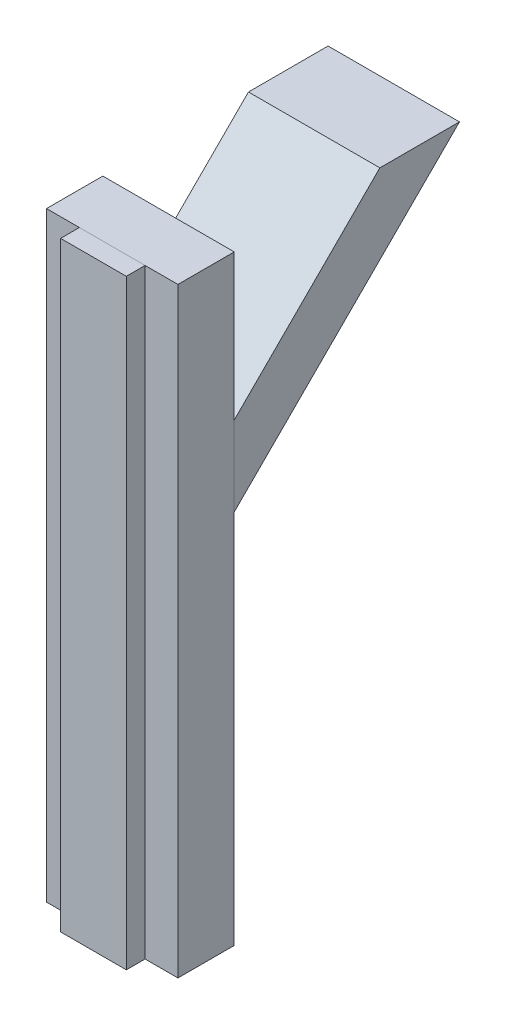
from build123d import *

# Parameters (mm, degrees)
SKETCH2_W              = 38.1
SKETCH2_H              = 406.4
SLIDER_BOARD_DEPTH     = 88.9
DIAGONAL_SUPPORT_DEPTH = 88.9
SKETCH4_W              = 44.45
SKETCH4_H              = 406.4
SLIDER_DEPTH           = 12.7


with BuildPart() as part:
    # Sketch2 → Slider_Board (new body)
    with BuildSketch(Plane(origin=(0, 0, 0), x_dir=(0, 0, -1), z_dir=(1, 0, 0))):
        with Locations((0, -203.2)):
            Rectangle(SKETCH2_W, SKETCH2_H)
    extrude(amount=SLIDER_BOARD_DEPTH)


with BuildPart() as body_2:
    # Sketch3 → Diagonal_Support (new body)
    with BuildSketch(Plane(origin=(0, 0, 0), x_dir=(0, 0, -1), z_dir=(1, 0, 0))):
        Polygon((19.05, -152.4), (171.45, 0), (117.568463274, 0), (19.05, -98.518463274), align=None)
    extrude(amount=DIAGONAL_SUPPORT_DEPTH)


with BuildPart() as body_3:
    # Sketch4 → Slider (new body)
    with BuildSketch(Plane.XY.offset(19.05)):
        with Locations((44.45, -203.2)):
            Rectangle(SKETCH4_W, SKETCH4_H)
    extrude(amount=SLIDER_DEPTH)


solid = Compound([part.part, body_2.part, body_3.part])
